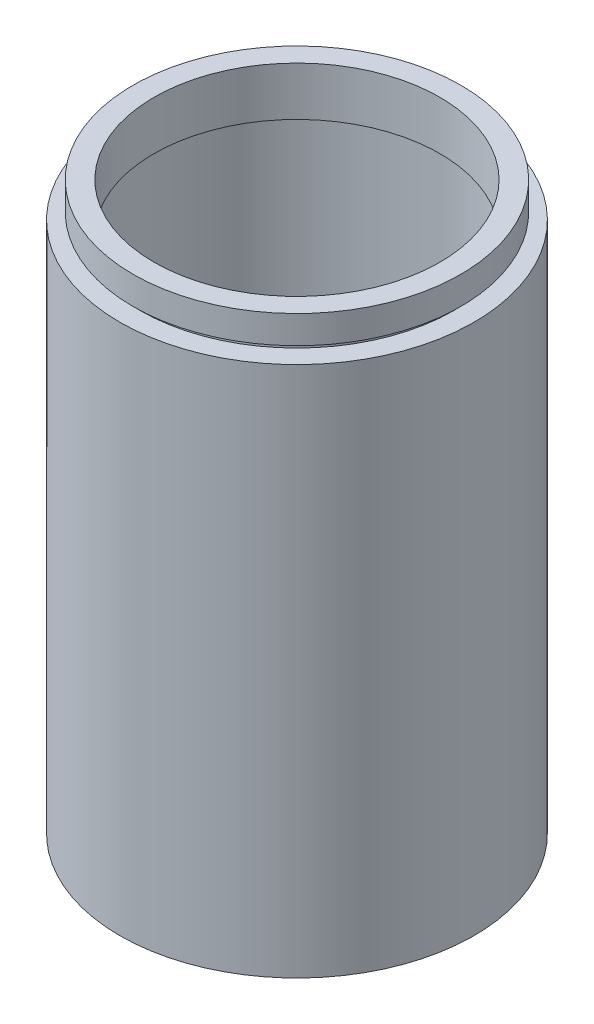
from build123d import *


with BuildPart() as part:
    # 草图1 → 旋转1 (revolve)
    with BuildSketch(Plane.XY, mode=Mode.PRIVATE) as revolve_1_sk:
        Polygon((22.5, 73.2), (23.5, 73.2), (23.5, 74.2), (20.5, 74.2), (20.5, 81.2), (23.5, 81.2), (23.5, 77.2), (22.5, 77.2), (22.5, 76.2), (23.5, 76.2), (25.4, 76.2), (25.4, 0), (22.5, 0), (22.5, 5.5), (23.5, 5.5), (23.5, 6.5), (22.5, 6.5), align=None)
    revolve(revolve_1_sk.sketch.rotate(Axis((0, 161.376166943, 0), (0, -1, 0)), 90), axis=Axis((0, 161.376166943, 0), (0, -1, 0)))  # turned: the seam where the file's is


solid = part.part
